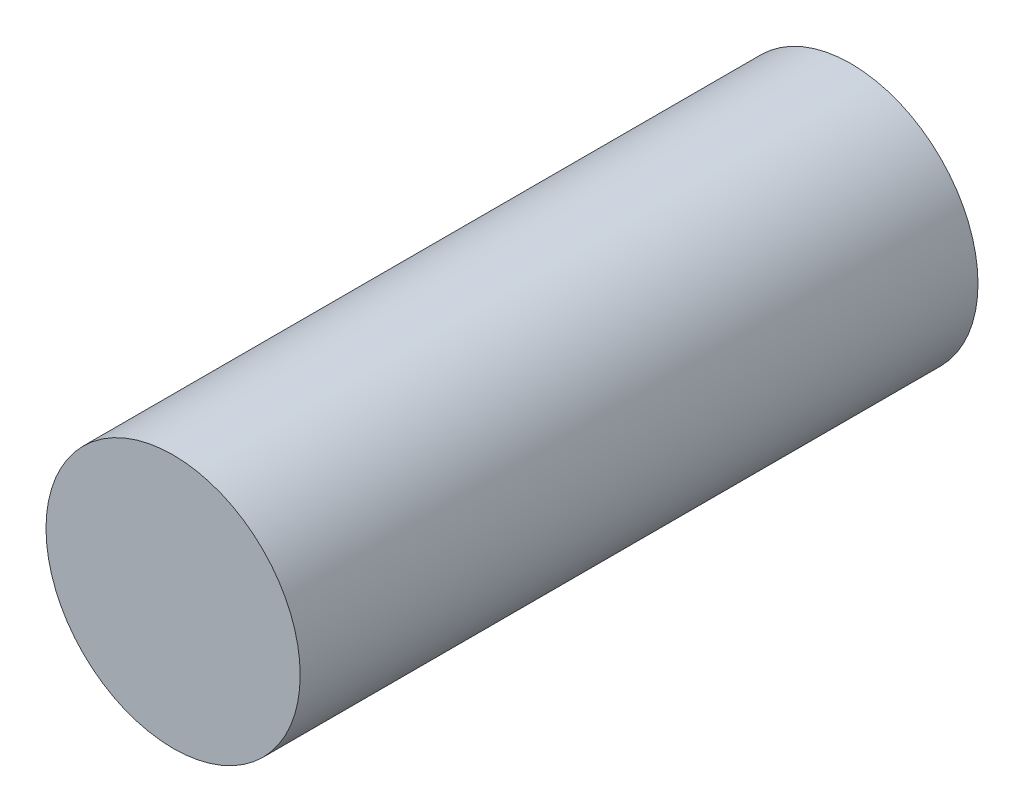
from build123d import *

# Parameters (mm, degrees)
SKETCH1_R           = 4.7625
BOSS_EXTRUDE1_DEPTH = 25.4


with BuildPart() as part:
    # Sketch1 → Boss-Extrude1 (new body)
    with BuildSketch(Plane.XY):
        Circle(SKETCH1_R)
    extrude(amount=BOSS_EXTRUDE1_DEPTH)


solid = part.part
